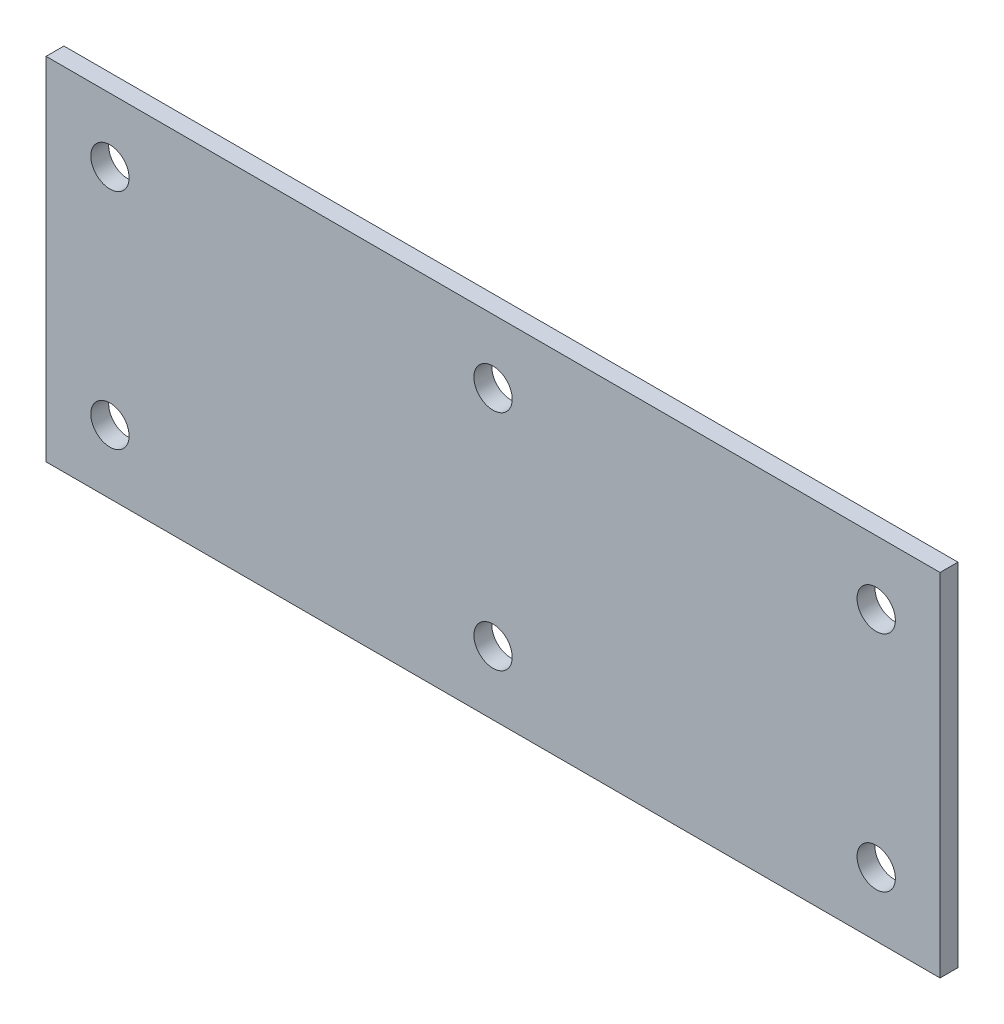
from build123d import *

# Parameters (mm, degrees)
SKETCH1_W           = 88.9
SKETCH1_H           = 34.925
BOSS_EXTRUDE1_DEPTH = 1.778
SKETCH2_R           = 1.905
CUT_EXTRUDE1_DEPTH  = 2.778


with BuildPart() as part:
    # Sketch1 → Boss-Extrude1 (new body)
    with BuildSketch(Plane.XY):
        Rectangle(SKETCH1_W, SKETCH1_H)
    extrude(amount=BOSS_EXTRUDE1_DEPTH)

    # Sketch2 → Cut-Extrude1 (cut, through all)
    with BuildSketch(Plane.XY.offset(1.778)):
        with Locations((0, 11.1125)):
            Circle(SKETCH2_R)
        with Locations((-38.1, 11.1125)):
            Circle(SKETCH2_R)
        with Locations((-38.1, -11.1125)):
            Circle(SKETCH2_R)
        with Locations((0, -11.1125)):
            Circle(SKETCH2_R)
        with Locations((38.1, -11.1125)):
            Circle(SKETCH2_R)
        with Locations((38.1, 11.1125)):
            Circle(SKETCH2_R)
    extrude(amount=-CUT_EXTRUDE1_DEPTH, mode=Mode.SUBTRACT)


solid = part.part
